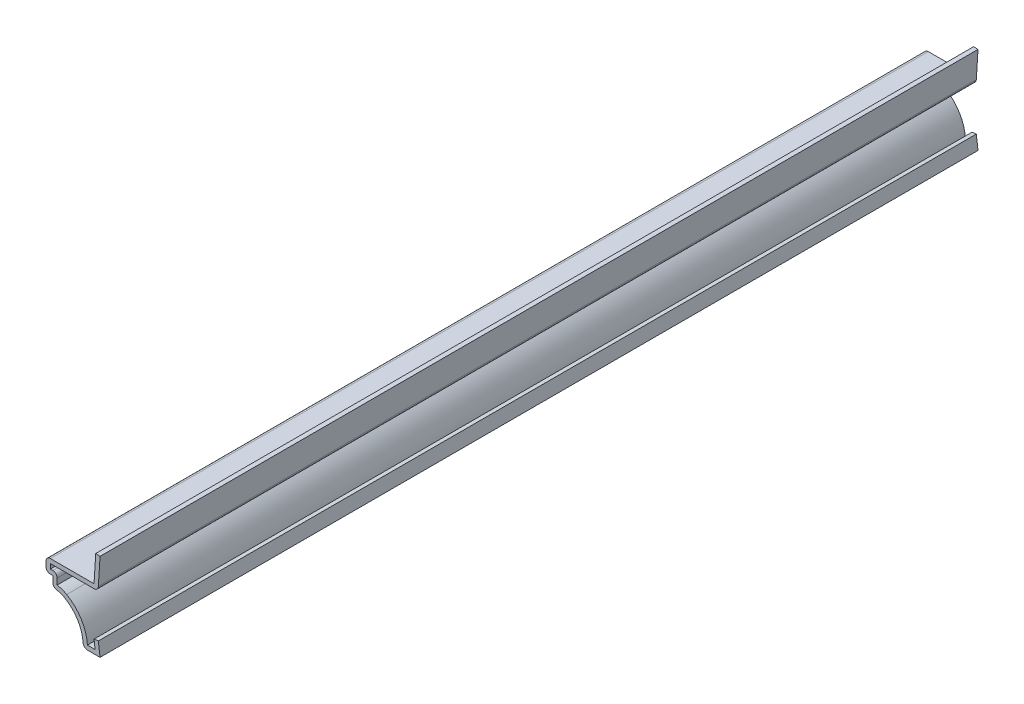
from build123d import *

# Parameters (mm, degrees)
EXTRUDE_THIN1_DEPTH = 206.375
FILLET1_R           = 1.016


with BuildPart() as part:
    # Sketch1 → Extrude-Thin1 (new body)
    with BuildSketch(Plane.XY):
        with BuildLine():
            Line((-0.396875, 3.150097655), (0, 0))
            Line((0, 0), (-3.96875, 0))
            ThreePointArc((-3.96875, 0), (-5.03336677, 4.616238484), (-8.352026926, 7.997001915))
            ThreePointArc((-8.352026926, 7.997001915), (-9.684272791, 8.544551294), (-11.1125, 8.73125))
            Line((-11.1125, 8.73125), (-11.1125, 11.1125))
            Line((-11.1125, 11.1125), (-12.7, 11.1125))
            Line((-12.7, 11.1125), (-12.7, 14.2875))
            Line((-12.7, 14.2875), (-1.41089642, 14.2875))
            Line((-1.41089642, 14.2875), (-1.01402142, 20.6375))
            Line((-1.01402142, 20.6375), (0, 20.574123661))
            Line((0, 20.574123661), (-0.456413979, 13.2715))
            Line((-0.456413979, 13.2715), (-11.684, 13.2715))
            Line((-11.684, 13.2715), (-11.684, 12.1285))
            Line((-11.684, 12.1285), (-10.0965, 12.1285))
            Line((-10.0965, 12.1285), (-10.0965, 9.668243724))
            ThreePointArc((-10.0965, 9.668243724), (-8.935783532, 9.376320463), (-7.847254707, 8.878739409))
            ThreePointArc((-7.847254707, 8.878739409), (-4.411092734, 5.564472131), (-2.960927924, 1.016))
            Line((-2.960927924, 1.016), (-1.152035714, 1.016))
            Line((-1.152035714, 1.016), (-1.40490625, 3.023097655))
            Line((-1.40490625, 3.023097655), (-0.396875, 3.150097655))
        make_face()
    extrude(amount=-EXTRUDE_THIN1_DEPTH)

    # Fillet1
    fillet1_edges = [part.edges().sort_by_distance(p)[0] for p in [
        (-0.456413979, 13.2715, -103.1875),
        (-10.0965, 12.1285, -103.1875),
        (-3.96875, 0, -103.1875),
        (-11.1125, 8.73125, -103.1875),
        (-12.7, 11.1125, -103.1875),
        (-12.7, 14.2875, -103.1875),
    ]]
    fillet(fillet1_edges, radius=FILLET1_R)


solid = part.part
